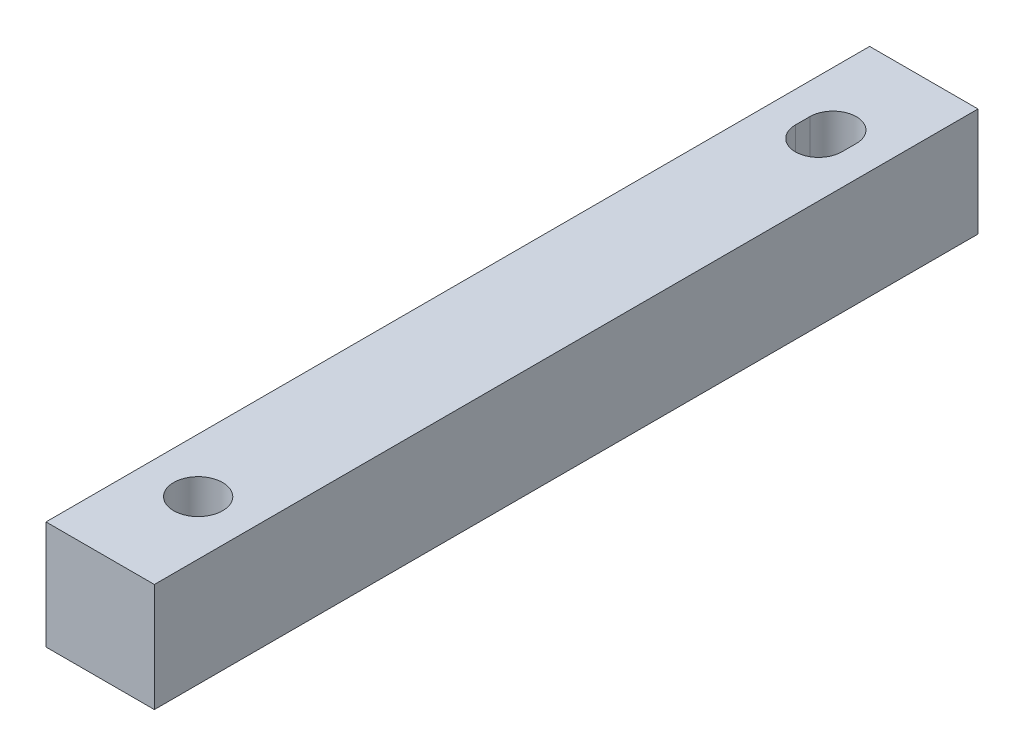
from build123d import *

# Parameters (mm, degrees)
SKETCH1_W                        = 9.525
SKETCH1_H                        = 72.39
BOSS_EXTRUDE1_DEPTH              = 9.525
F_18_0_1695_DIAMETER_HOLE1_D     = 4.3053
F_18_0_1695_DIAMETER_HOLE1_DEPTH = 15.24
F_18_0_1695_DIAMETER_HOLE1_TIP   = 1.293442612
CUT_EXTRUDE1_REACH               = 11.525


with BuildPart() as part:
    # Sketch1 → Boss-Extrude1 (new body)
    with BuildSketch(Plane(origin=(0, 0, 0), x_dir=(1, 0, 0), z_dir=(0, 1, 0))):
        with Locations((-20.976080696, -16.361756412)):
            Rectangle(SKETCH1_W, SKETCH1_H)
    extrude(amount=BOSS_EXTRUDE1_DEPTH)

    # #18 (0.1695) Diameter Hole1
    with Locations(Plane(origin=(0, 9.525, 0), x_dir=(-1, 0, 0), z_dir=(0, 1, 0))):
        with Locations((20.976080696, 43.944568912)):
            Hole(F_18_0_1695_DIAMETER_HOLE1_D / 2, depth=F_18_0_1695_DIAMETER_HOLE1_DEPTH)
            with Locations((0, 0, -(F_18_0_1695_DIAMETER_HOLE1_DEPTH + F_18_0_1695_DIAMETER_HOLE1_TIP / 2))):  # 118° drill point
                Cone(0, F_18_0_1695_DIAMETER_HOLE1_D / 2, F_18_0_1695_DIAMETER_HOLE1_TIP, mode=Mode.SUBTRACT)

    # Sketch4 → Cut-Extrude1 (cut, up to next)
    with BuildSketch(Plane(origin=(0, 9.525, 0), x_dir=(1, 0, 0), z_dir=(0, 1, 0)), mode=Mode.PRIVATE) as cut_extrude1_sk1:
        with BuildLine():
            Line((-18.9306781, 11.856056088), (-18.9306781, 10.586056088))
            ThreePointArc((-18.9306781, 10.586056088), (-20.976080696, 8.540653493), (-23.021483291, 10.586056088))
            Line((-23.021483291, 10.586056088), (-23.021483291, 11.856056088))
            ThreePointArc((-23.021483291, 11.856056088), (-20.976080696, 13.901458684), (-18.9306781, 11.856056088))
        make_face()
    cut_extrude1_tool1 = extrude(cut_extrude1_sk1.sketch, amount=-CUT_EXTRUDE1_REACH, mode=Mode.PRIVATE) & part.part
    add(cut_extrude1_tool1.solids().sort_by_distance((-20.976081, 9.525, -11.221056))[0], mode=Mode.SUBTRACT)


solid = part.part
